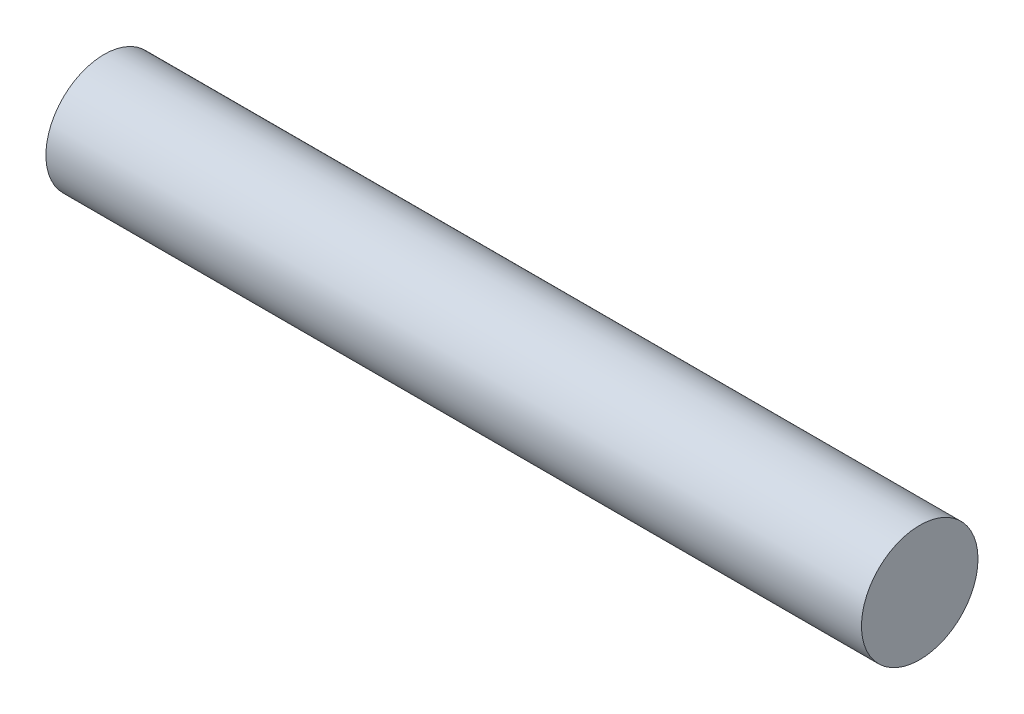
from build123d import *

# Parameters (mm, degrees)
SKIZZE1_R               = 1
LINEAR_AUSTRAGEN1_DEPTH = 7


with BuildPart() as part:
    # Skizze1 → Linear austragen1 (new body, symmetric)
    with BuildSketch(Plane(origin=(0, 0, 0), x_dir=(0, 0, -1), z_dir=(1, 0, 0))):
        Circle(SKIZZE1_R)
    extrude(amount=LINEAR_AUSTRAGEN1_DEPTH, both=True)


solid = part.part
